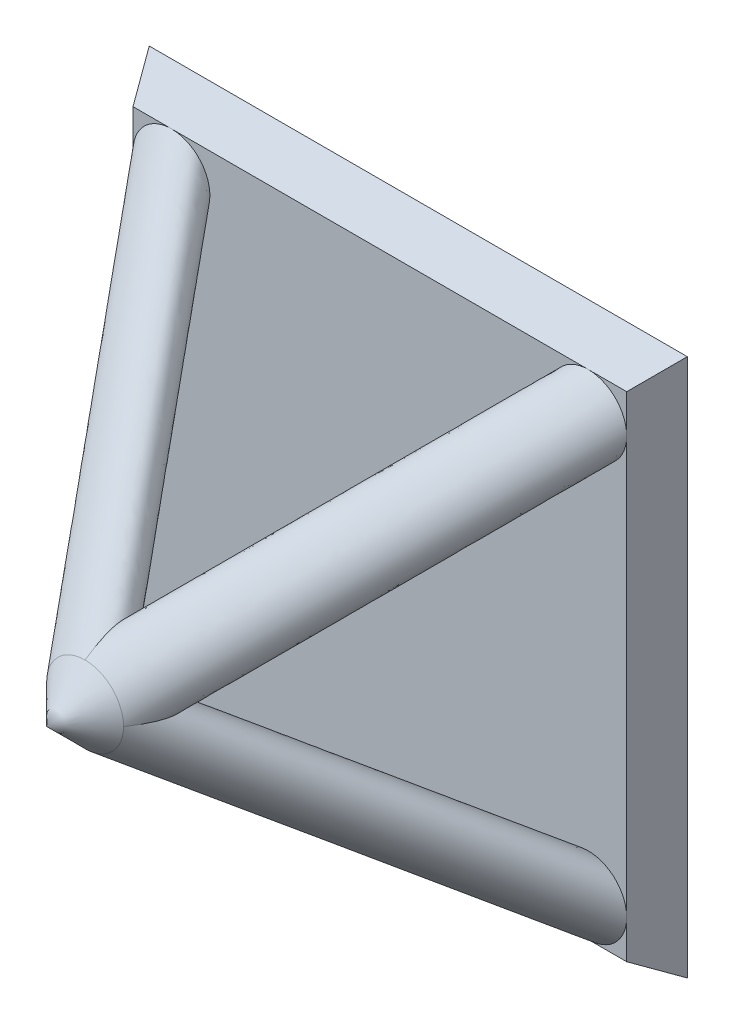
from build123d import *

# Parameters (mm, degrees)
SKETCH1_W           = 14
SKETCH1_H           = 14
BOSS_EXTRUDE1_DEPTH = 1
BOSS_EXTRUDE1_TAPER = 30
SKETCH2_R           = 1
CIRPATTERN1_COUNT   = 4
SKETCH4_R           = 1
BOSS_EXTRUDE2_DEPTH = 10
BOSS_EXTRUDE2_TAPER = 45
SCALE1_SCALE        = 0.5


with BuildPart() as part:
    # Sketch1 → Boss-Extrude1 (new body)
    with BuildSketch(Plane.XY):
        Rectangle(SKETCH1_W, SKETCH1_H)
    extrude(amount=BOSS_EXTRUDE1_DEPTH, taper=BOSS_EXTRUDE1_TAPER)

    # Sweep1: sweep along a path in Sketch3
    with BuildLine(Plane(origin=(0, 0, 0), x_dir=(0, 0, -1), z_dir=(0.707106781, -0.707106781, 0))) as sweep1_path:
        Line((-1, 7.668784793), (-8.668784793, 0))
    # Sketch2 → Sweep1 (sweep)
    with BuildSketch(Plane.XY.offset(1)):
        with Locations((5.422649731, 5.422649731)):
            Circle(SKETCH2_R)
    sweep1 = sweep(path=sweep1_path.line)

    # CirPattern1: Sweep1 ×4 about axis
    cirpattern1_axis = Axis((0, 0, -4.23184126), (0, 0, 1))
    for i in range(1, CIRPATTERN1_COUNT):
        add(sweep1.rotate(cirpattern1_axis, i * 360 / CIRPATTERN1_COUNT))

    # Sketch4 → Boss-Extrude2 (add)
    with BuildSketch(Plane.XY.offset(8.668784793)):
        Circle(SKETCH4_R)
    extrude(amount=BOSS_EXTRUDE2_DEPTH, taper=BOSS_EXTRUDE2_TAPER)


with BuildPart() as part_1:
    # Scale1: scaled about (-3.3e-08, 4.07e-07, 1.879504051)
    add(part.part.scale(SCALE1_SCALE).moved(Location((-1.6e-08, 2.03e-07, 0.939752026))))


solid = part_1.part
